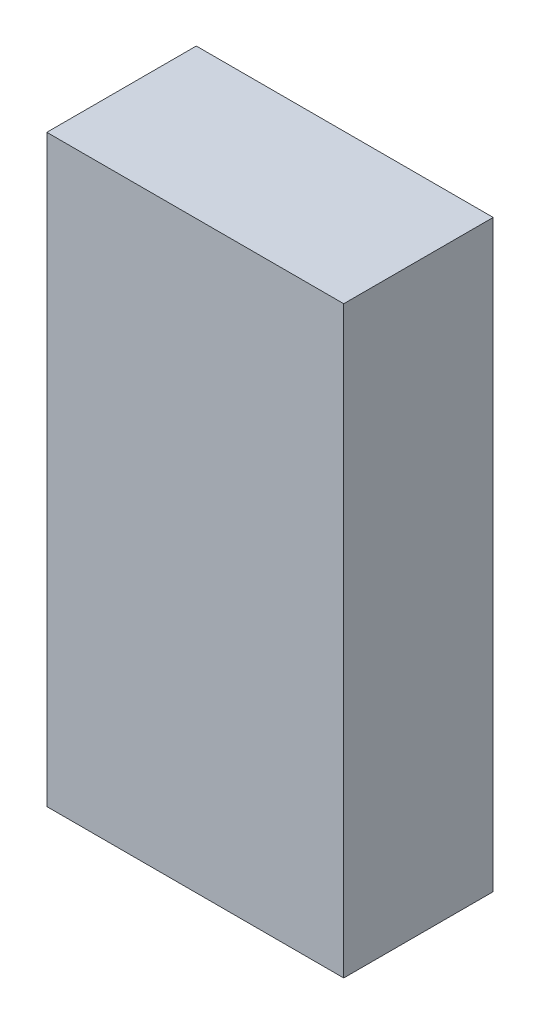
from build123d import *

# Parameters (mm, degrees)
ESQUISSE1_W        = 85.42
ESQUISSE1_H        = 168
BOSS_EXTRU_1_DEPTH = 43


with BuildPart() as part:
    # Esquisse1 → Boss.-Extru.1 (new body)
    with BuildSketch(Plane.XY):
        with Locations((-53.352463609, -18.991304348)):
            Rectangle(ESQUISSE1_W, ESQUISSE1_H)
    extrude(amount=BOSS_EXTRU_1_DEPTH)


solid = part.part
